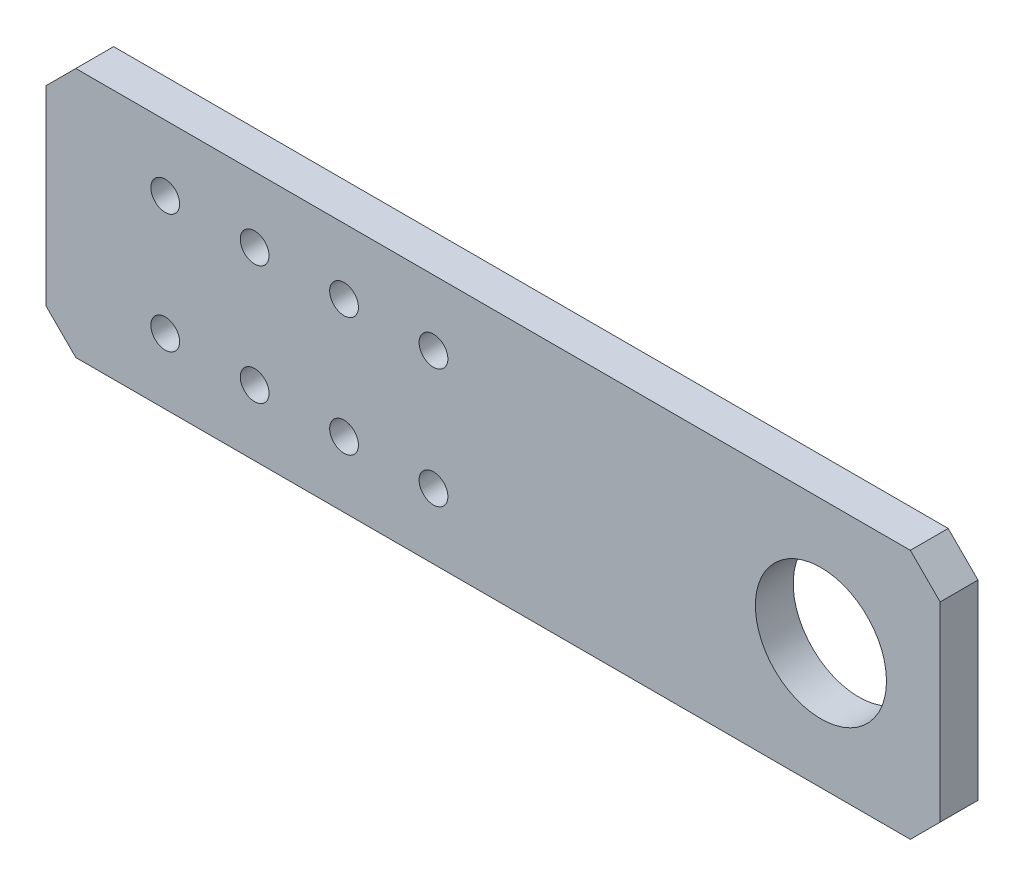
from build123d import *

# Parameters (mm, degrees)
SKETCH1_W           = 205
SKETCH1_H           = 42
BOSS_EXTRUDE1_DEPTH = 6.35
SKETCH4_R           = 11
CUT_EXTRUDE3_DEPTH  = 7.35
CHAMFER1_SIZE       = 5
SKETCH9_R           = 11
CUT_EXTRUDE8_DEPTH  = 7.35
SKETCH14_R          = 11
SKETCH14_R_2        = 2.413
CUT_EXTRUDE10_DEPTH = 10


with BuildPart() as part:
    # Sketch1 → Boss-Extrude1 (new body)
    with BuildSketch(Plane.XY):
        Rectangle(SKETCH1_W, SKETCH1_H)
    extrude(amount=BOSS_EXTRUDE1_DEPTH)

    # Sketch4 → Cut-Extrude3 (cut, through all)
    with BuildSketch(Plane.XY.offset(6.35)):
        with Locations((-78.5, 0)):
            Circle(SKETCH4_R)
    extrude(amount=-CUT_EXTRUDE3_DEPTH, mode=Mode.SUBTRACT)

    # Chamfer1
    chamfer1_edges = [part.edges().sort_by_distance(p)[0] for p in [
        (102.5, -21, 3.175),
        (-102.5, -21, 3.175),
        (-102.5, 21, 3.175),
        (102.5, 21, 3.175),
    ]]
    chamfer(chamfer1_edges, length=CHAMFER1_SIZE)

    # Sketch9 → Cut-Extrude8 (cut, through all)
    with BuildSketch(Plane.XY.offset(6.35)):
        with Locations((82.5, 0)):
            Circle(SKETCH9_R)
    extrude(amount=-CUT_EXTRUDE8_DEPTH, mode=Mode.SUBTRACT)

    # Sketch14 → Cut-Extrude10 (cut)
    with BuildSketch(Plane.XY.offset(6.35)):
        Polygon((-47.5, -16), (-47.5, 16), (-42.5, 21), (-97.5, 21), (-102.5, 16), (-102.5, -16), (-97.5, -21), (-42.5, -21), align=None)
        with Locations((-78.5, 0)):
            Circle(SKETCH14_R, mode=Mode.SUBTRACT)
        with Locations((-27.5, 10)):
            Circle(SKETCH14_R_2)
        with Locations((-27.5, -10)):
            Circle(SKETCH14_R_2)
        with Locations((-12.5, -10)):
            Circle(SKETCH14_R_2)
        with Locations((-12.5, 10)):
            Circle(SKETCH14_R_2)
        with Locations((17.5, 10)):
            Circle(SKETCH14_R_2)
        with Locations((2.5, -10)):
            Circle(SKETCH14_R_2)
        with Locations((17.5, -10)):
            Circle(SKETCH14_R_2)
        with Locations((2.5, 10)):
            Circle(SKETCH14_R_2)
    extrude(amount=-CUT_EXTRUDE10_DEPTH, mode=Mode.SUBTRACT)


solid = part.part
